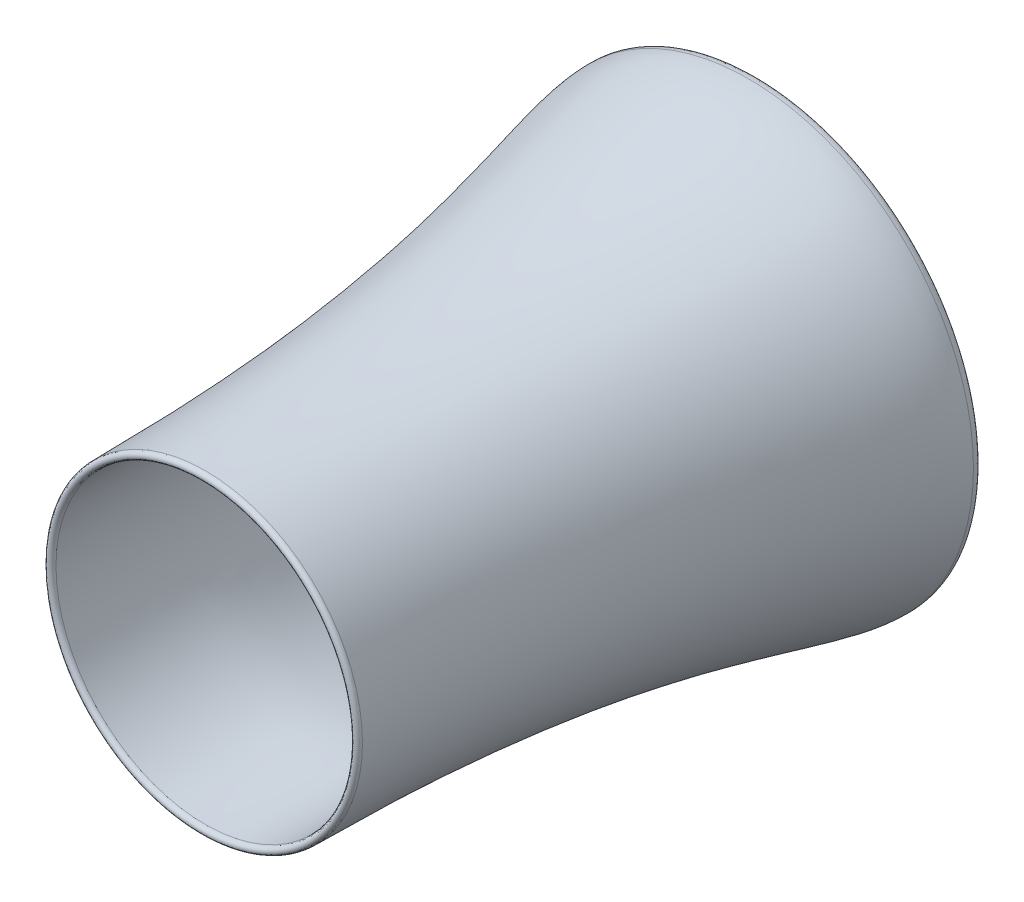
from build123d import *


with BuildPart() as part:
    # Sketch21 → 旋转1 (revolve)
    with BuildSketch(Plane(origin=(0, 0, 0), x_dir=(1, 0, 0), z_dir=(0, 1, 0))):
        with BuildLine():
            Line((-110.643738414, -1084.892826606), (-126.781859006, -1084.892826606))
            add(Edge.make_bspline(
                [(-267.236857749, 45.462198325), (-267.236857749, -79.921754051), (-126.781859006, -354.583706221), (-126.781859006, -1084.892826606)],
                knots=[0, 0, 0, 0, 1, 1, 1, 1], degree=3))
            Line((-267.236857749, 45.462198325), (-259.495458194, 45.462198325))
            add(Edge.make_bspline(
                [(-259.495458194, 45.462198325), (-259.495458194, -7.173554197), (-207.747704143, -105.812239727), (-173.314715973, -383.138357007), (-92.422811238, -818.96889363), (-110.643738414, -795.784205966), (-110.643738414, -1084.892826606)],
                knots=[0, 0, 0, 0, 0.158009172, 0.206506907, 0.484977351, 1, 1, 1, 1], degree=3))
        make_face()
    revolve(axis=Axis((200, 0, -115.791199572), (0, 0, 1)))

    # Sketch22 → 旋转2 (revolve)
    with BuildSketch(Plane(origin=(0, 0, 0), x_dir=(1, 0, 0), z_dir=(0, 1, 0))):
        with BuildLine():
            Line((-267.236857749, 45.462198325), (-259.495458194, 45.462198325))
            add(Edge.make_bspline(
                [(-267.236857749, 45.462198325), (-267.236857749, 62.395531659), (-259.495458194, 62.395531659), (-259.495458194, 45.462198325)],
                knots=[0, 0, 0, 0, 1, 1, 1, 1], degree=3))
        make_face()
    revolve(axis=Axis((200, 0, -115.791199572), (0, 0, 1)))

    # Sketch23 → 旋转3 (revolve)
    with BuildSketch(Plane(origin=(0, 0, 0), x_dir=(1, 0, 0), z_dir=(0, 1, 0))):
        with BuildLine():
            Line((-126.781859006, -1084.892826606), (-110.643738414, -1084.892826606))
            add(Edge.make_bspline(
                [(-126.781859006, -1084.892826606), (-126.781859006, -1097.592826606), (-110.643738414, -1097.592826606), (-110.643738414, -1084.892826606)],
                knots=[0, 0, 0, 0, 1, 1, 1, 1], degree=3))
        make_face()
    revolve(axis=Axis((200, 0, -115.791199572), (0, 0, 1)))


solid = part.part
